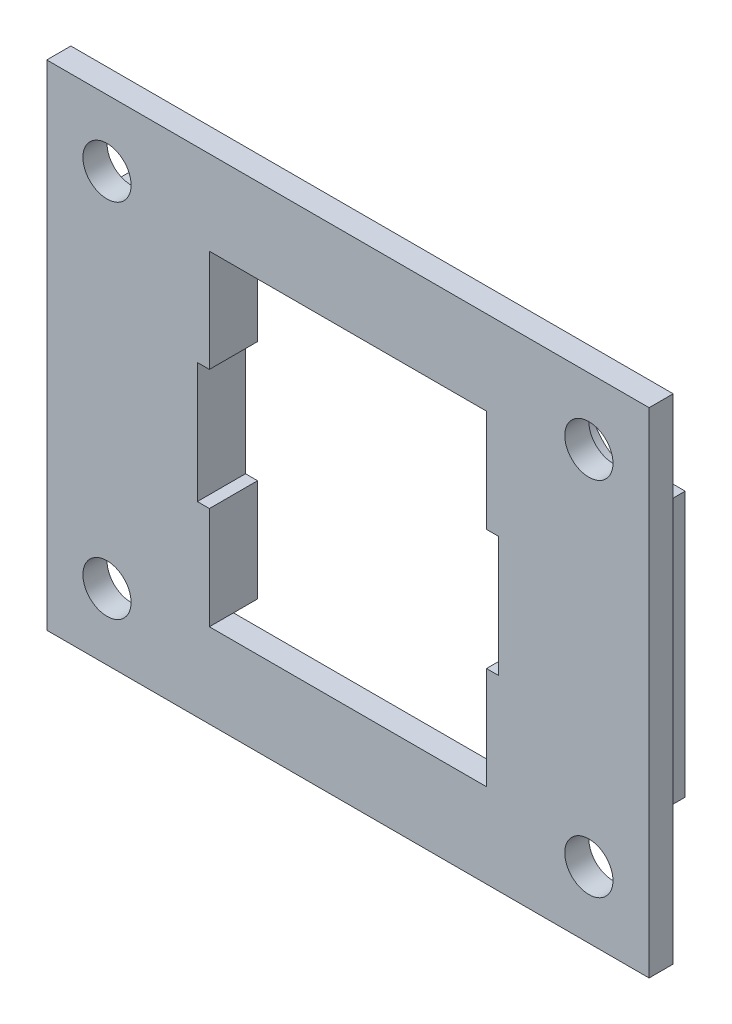
from build123d import *

# Parameters (mm, degrees)
SKETCH3_W               = 50
SKETCH3_H               = 35
BOSS_EXTRUDE2_DEPTH     = 8
CUT_EXTRUDE1_DEPTH      = 6
LPATTERN1_COUNT         = 2
LPATTERN1_PITCH         = 15.5
LPATTERN1_COUNT_DIR2    = 2
LPATTERN1_PITCH_DIR2    = 30.51
SKETCH4_W               = 50
SKETCH4_H               = 35
SKETCH4_W_2             = 42
SKETCH4_H_2             = 27
CUT_EXTRUDE2_DEPTH      = 6
SKETCH5_W               = 25
SKETCH5_H               = 10
CUT_EXTRUDE4_DEPTH      = 24
SKETCH6_R               = 2
CUT_EXTRUDE5_DEPTH      = 24
CUT_EXTRUDE6_DEPTH      = 24
MIRROR2_COPY_1_SKETCH_R = 2
MIRROR2_COPY_1_DEPTH    = 24
MIRROR2_COPY_2_DEPTH    = 24
SKETCH9_W               = 50
SKETCH9_H               = 41
SKETCH9_R               = 2
SKETCH9_W_2             = 25
SKETCH9_H_2             = 10
BOSS_EXTRUDE4_DEPTH     = 2
SKETCH10_W              = 43
SKETCH10_H              = 28
CUT_EXTRUDE7_DEPTH      = 4
SKETCH11_W              = 2
SKETCH11_H              = 22
BOSS_EXTRUDE5_DEPTH     = 3
SKETCH12_W              = 23
SKETCH12_H              = 27
CUT_EXTRUDE8_DEPTH      = 17


with BuildPart() as part:
    # Sketch3 → Boss-Extrude2 (new body)
    with BuildSketch(Plane.XY):
        with Locations((15, 7.5)):
            Rectangle(SKETCH3_W, SKETCH3_H)
    extrude(amount=BOSS_EXTRUDE2_DEPTH)

    # Sketch1 → Cut-Extrude1 (cut)
    with BuildSketch(Plane.XY):
        with BuildLine():
            ThreePointArc((0.398416619, 17.214444444), (0, 16.85), (-0.398416619, 17.214444444))
            ThreePointArc((-0.398416619, 17.214444444), (-0.467801304, 17.200832102), (-0.536724007, 17.185046302))
            ThreePointArc((-0.536724007, 17.185046302), (-0.75246279, 16.690059097), (-1.264667392, 16.860945025))
            ThreePointArc((-1.264667392, 16.860945025), (-1.322516818, 16.820288237), (-1.379060176, 16.777833803))
            ThreePointArc((-1.379060176, 16.777833803), (-1.374817927, 16.237891622), (-1.912245684, 16.185671305))
            ThreePointArc((-1.912245684, 16.185671305), (-1.948557159, 16.125), (-1.982944313, 16.063217688))
            ThreePointArc((-1.982944313, 16.063217688), (-1.759454555, 15.57168144), (-2.229179325, 15.305384245))
            ThreePointArc((-2.229179325, 15.305384245), (-2.237674265, 15.235189042), (-2.243959363, 15.164761577))
            ThreePointArc((-2.243959363, 15.164761577), (-1.839865506, 14.806622343), (-2.160667609, 14.372293474))
            ThreePointArc((-2.160667609, 14.372293474), (-2.139877162, 14.304711763), (-2.116973454, 14.237816691))
            ThreePointArc((-2.116973454, 14.237816691), (-1.602146997, 14.075), (-1.718556835, 13.547738864))
            ThreePointArc((-1.718556835, 13.547738864), (-1.672075857, 13.494456136), (-1.623943602, 13.442660224))
            ThreePointArc((-1.623943602, 13.442660224), (-1.087402717, 13.50331856), (-0.979291971, 12.974293398))
            ThreePointArc((-0.979291971, 12.974293398), (-0.915157447, 12.94452272), (-0.850119149, 12.916781953))
            ThreePointArc((-0.850119149, 12.916781953), (-0.384636628, 13.190426939), (-0.070698628, 12.751111007))
            ThreePointArc((-0.070698628, 12.751111007), (0, 12.75), (0.070698628, 12.751111007))
            ThreePointArc((0.070698628, 12.751111007), (0.384636628, 13.190426939), (0.850119149, 12.916781953))
            ThreePointArc((0.850119149, 12.916781953), (0.915157447, 12.94452272), (0.979291971, 12.974293398))
            ThreePointArc((0.979291971, 12.974293398), (1.087402717, 13.50331856), (1.623943602, 13.442660224))
            ThreePointArc((1.623943602, 13.442660224), (1.672075857, 13.494456136), (1.718556835, 13.547738864))
            ThreePointArc((1.718556835, 13.547738864), (1.602146997, 14.075), (2.116973454, 14.237816691))
            ThreePointArc((2.116973454, 14.237816691), (2.139877162, 14.304711763), (2.160667609, 14.372293474))
            ThreePointArc((2.160667609, 14.372293474), (1.839865506, 14.806622343), (2.243959363, 15.164761577))
            ThreePointArc((2.243959363, 15.164761577), (2.237674265, 15.235189042), (2.229179325, 15.305384245))
            ThreePointArc((2.229179325, 15.305384245), (1.759454555, 15.57168144), (1.982944313, 16.063217688))
            ThreePointArc((1.982944313, 16.063217688), (1.948557159, 16.125), (1.912245684, 16.185671305))
            ThreePointArc((1.912245684, 16.185671305), (1.374817927, 16.237891622), (1.379060176, 16.777833803))
            ThreePointArc((1.379060176, 16.777833803), (1.322516818, 16.820288237), (1.264667392, 16.860945025))
            ThreePointArc((1.264667392, 16.860945025), (0.75246279, 16.690059097), (0.536724007, 17.185046302))
            ThreePointArc((0.536724007, 17.185046302), (0.467801304, 17.200832102), (0.398416619, 17.214444444))
        make_face()
    cut_extrude1 = extrude(amount=CUT_EXTRUDE1_DEPTH, mode=Mode.SUBTRACT)

    # LPattern1: Cut-Extrude1 2 × 2
    with Locations(*[(j * LPATTERN1_PITCH_DIR2, -i * LPATTERN1_PITCH, 0) for i in range(LPATTERN1_COUNT) for j in range(LPATTERN1_COUNT_DIR2) if (i, j) != (0, 0)]):
        add(cut_extrude1, mode=Mode.SUBTRACT)

    # Sketch4 → Cut-Extrude2 (cut)
    with BuildSketch(Plane(origin=(0, 0, 0), x_dir=(-1, 0, 0), z_dir=(0, 0, -1))):
        with Locations((-15, 7.5)):
            Rectangle(SKETCH4_W, SKETCH4_H)
        with Locations((-15, 7.5)):
            Rectangle(SKETCH4_W_2, SKETCH4_H_2, mode=Mode.SUBTRACT)
    extrude(amount=-CUT_EXTRUDE2_DEPTH, mode=Mode.SUBTRACT)

    # Sketch5 → Cut-Extrude4 (cut)
    with BuildSketch(Plane(origin=(0, 0, 0), x_dir=(-1, 0, 0), z_dir=(0, 0, -1))):
        with Locations((-15, 7.5)):
            Rectangle(SKETCH5_W, SKETCH5_H)
    extrude(amount=-CUT_EXTRUDE4_DEPTH, mode=Mode.SUBTRACT)

    # Sketch6 → Cut-Extrude5 (cut, symmetric)
    with BuildSketch(Plane(origin=(0, 0, 6), x_dir=(-1, 0, 0), z_dir=(0, 0, -1))):
        with Locations((5, 22.5)):
            Circle(SKETCH6_R)
    cut_extrude5 = extrude(amount=CUT_EXTRUDE5_DEPTH, both=True, mode=Mode.SUBTRACT)

    # Sketch7 → Cut-Extrude6 (cut)
    with BuildSketch(Plane(origin=(0, 0, 6), x_dir=(-1, 0, 0), z_dir=(0, 0, -1))):
        with BuildLine():
            Line((5, 25), (10, 25))
            Line((10, 25), (10, 20.5))
            Line((10, 20.5), (10, 18.5))
            Line((10, 18.5), (5, 18.5))
            ThreePointArc((5, 18.5), (2.763932023, 19.18337521), (1.291900756, 21))
            Line((1.291900756, 21), (1.291900756, 25))
            Line((1.291900756, 25), (5, 25))
        make_face()
    cut_extrude6 = extrude(amount=CUT_EXTRUDE6_DEPTH, mode=Mode.SUBTRACT)

    # Mirror1: Cut-Extrude5, Cut-Extrude6 across plane
    add(cut_extrude5.mirror(Plane.ZY.offset(-15)), mode=Mode.SUBTRACT)
    add(cut_extrude6.mirror(Plane.ZY.offset(-15)), mode=Mode.SUBTRACT)

    # Mirror2: Cut-Extrude5, Cut-Extrude6 across plane
    add(cut_extrude5.mirror(Plane(origin=(0, 7.5, 0), x_dir=(0, 0, 1), z_dir=(0, -1, 0))), mode=Mode.SUBTRACT)
    add(cut_extrude6.mirror(Plane(origin=(0, 7.5, 0), x_dir=(0, 0, 1), z_dir=(0, -1, 0))), mode=Mode.SUBTRACT)

    # Mirror2 copy 1 sketch → Mirror2 copy 1 (cut, symmetric)
    with BuildSketch(Plane(origin=(30, 15, 6), x_dir=(1, 0, 0), z_dir=(0, 0, -1))):
        with Locations((5, 22.5)):
            Circle(MIRROR2_COPY_1_SKETCH_R)
    extrude(amount=MIRROR2_COPY_1_DEPTH, both=True, mode=Mode.SUBTRACT)

    # Mirror2 copy 2 sketch → Mirror2 copy 2 (cut)
    with BuildSketch(Plane(origin=(30, 15, 6), x_dir=(1, 0, 0), z_dir=(0, 0, -1))):
        with BuildLine():
            Line((5, 25), (10, 25))
            Line((10, 25), (10, 20.5))
            Line((10, 20.5), (10, 18.5))
            Line((10, 18.5), (5, 18.5))
            ThreePointArc((5, 18.5), (2.763932023, 19.18337521), (1.291900756, 21))
            Line((1.291900756, 21), (1.291900756, 25))
            Line((1.291900756, 25), (5, 25))
        make_face()
    extrude(amount=MIRROR2_COPY_2_DEPTH, mode=Mode.SUBTRACT)

    # Sketch9 → Boss-Extrude4 (add)
    with BuildSketch(Plane(origin=(0, 0, 6), x_dir=(-1, 0, 0), z_dir=(0, 0, -1))):
        with Locations((-15, 7.5)):
            Rectangle(SKETCH9_W, SKETCH9_H)
        with Locations((5, -7.5)):
            Circle(SKETCH9_R, mode=Mode.SUBTRACT)
        with Locations((-35, -7.5)):
            Circle(SKETCH9_R, mode=Mode.SUBTRACT)
        with Locations((5, 22.5)):
            Circle(SKETCH9_R, mode=Mode.SUBTRACT)
        with Locations((-35, 22.5)):
            Circle(SKETCH9_R, mode=Mode.SUBTRACT)
        with Locations((-15, 7.5)):
            Rectangle(SKETCH9_W_2, SKETCH9_H_2, mode=Mode.SUBTRACT)
    extrude(amount=-BOSS_EXTRUDE4_DEPTH)

    # Sketch10 → Cut-Extrude7 (cut)
    with BuildSketch(Plane(origin=(0, 0, 0), x_dir=(-1, 0, 0), z_dir=(0, 0, -1))):
        with Locations((-15, 7.5)):
            Rectangle(SKETCH10_W, SKETCH10_H)
    extrude(amount=-CUT_EXTRUDE7_DEPTH, mode=Mode.SUBTRACT)

    # Sketch11 → Boss-Extrude5 (add)
    with BuildSketch(Plane(origin=(0, 0, 6), x_dir=(-1, 0, 0), z_dir=(0, 0, -1))):
        with Locations((7, 7.5)):
            Rectangle(SKETCH11_W, SKETCH11_H)
        with Locations((-37, 7.5)):
            Rectangle(SKETCH11_W, SKETCH11_H)
    extrude(amount=BOSS_EXTRUDE5_DEPTH)

    # Sketch12 → Cut-Extrude8 (cut)
    with BuildSketch(Plane(origin=(0, 0, 4), x_dir=(-1, 0, 0), z_dir=(0, 0, -1))):
        with Locations((-15, 7.5)):
            Rectangle(SKETCH12_W, SKETCH12_H)
    extrude(amount=-CUT_EXTRUDE8_DEPTH, mode=Mode.SUBTRACT)


solid = part.part
